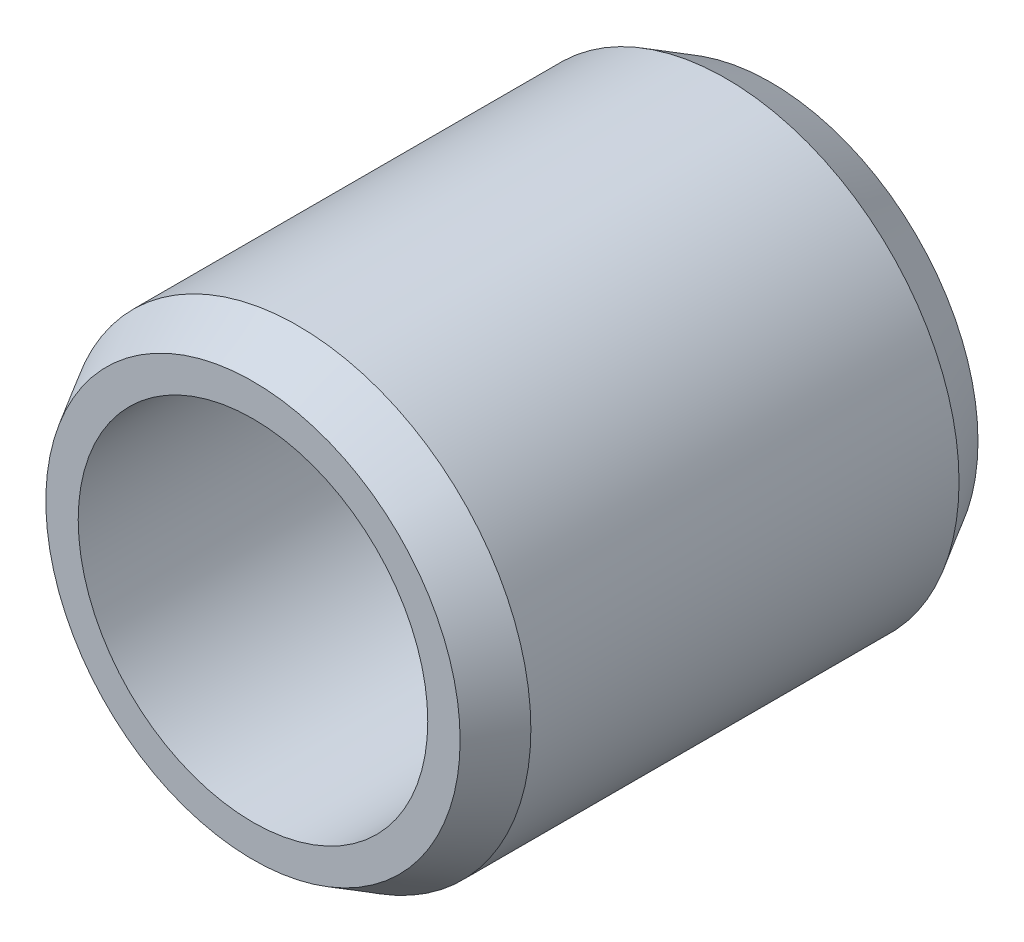
from build123d import *

# Parameters (mm, degrees)
SKETCH1_R             = 4.5
SKETCH1_R_2           = 3.375
BOSS_EXTRUDE1_DEPTH   = 10
CHAMFER1_SIZE         = 0.5
CHAMFER1_SIZE2        = 0.866025404
CHAMFER1_PART_2_SIZE  = 0.5
CHAMFER1_PART_2_SIZE2 = 0.866025404


with BuildPart() as part:
    # Sketch1 → Boss-Extrude1 (new body)
    with BuildSketch(Plane.XY):
        Circle(SKETCH1_R)
        Circle(SKETCH1_R_2, mode=Mode.SUBTRACT)
    extrude(amount=BOSS_EXTRUDE1_DEPTH)

    # Chamfer1
    chamfer1_edges = [part.edges().sort_by_distance(p)[0] for p in [
        (-4.5, 0, 0),
    ]]
    chamfer1_side = [part.faces().sort_by_distance(p)[0] for p in [
        (-4.372720779, 0, 0),
    ]]
    chamfer(chamfer1_edges, length=CHAMFER1_SIZE, length2=CHAMFER1_SIZE2, reference=chamfer1_side[0])

    # Chamfer1 part 2
    chamfer1_part_2_edges = [part.edges().sort_by_distance(p)[0] for p in [
        (-4.5, 0, 10),
    ]]
    chamfer1_part_2_side = [part.faces().sort_by_distance(p)[0] for p in [
        (-4.372720779, 0, 10),
    ]]
    chamfer(chamfer1_part_2_edges, length=CHAMFER1_PART_2_SIZE, length2=CHAMFER1_PART_2_SIZE2, reference=chamfer1_part_2_side[0])


solid = part.part
